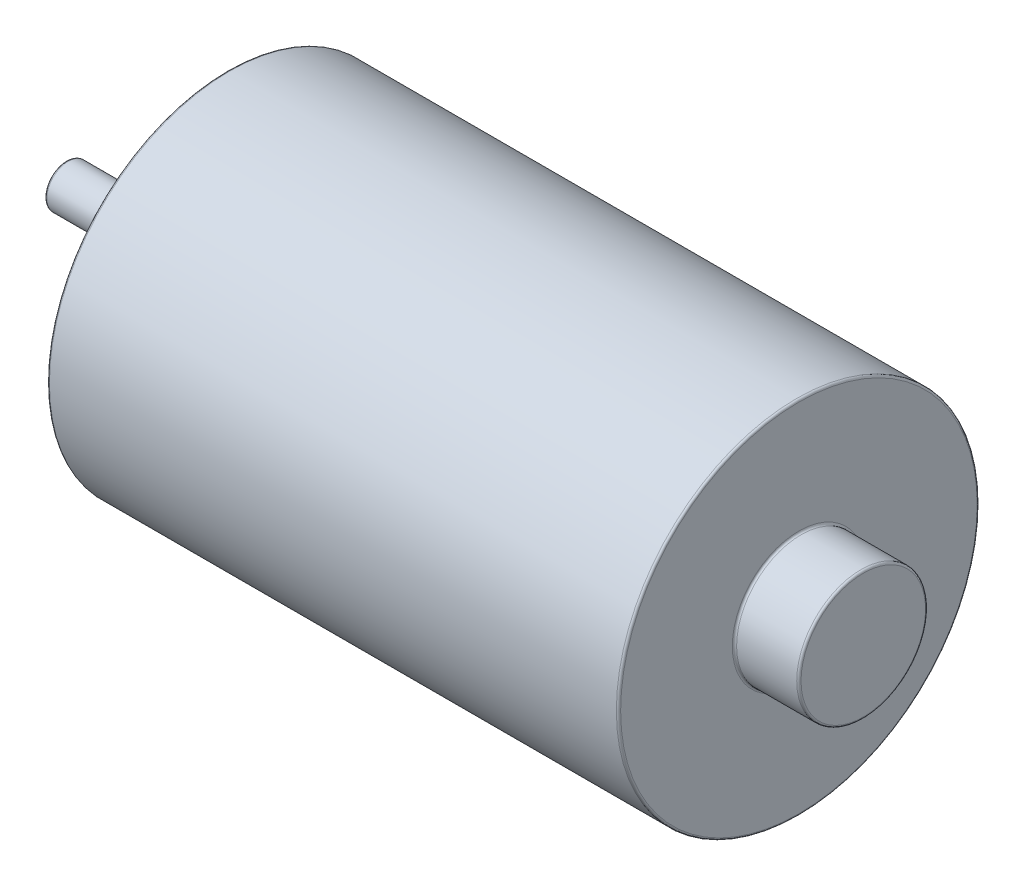
from build123d import *

# Parameters (mm, degrees)
FILLET1_R          = 0.25
SKETCH4_R          = 2
CUT_EXTRUDE2_DEPTH = 10


with BuildPart() as part:
    # Sketch1 → Revolve1 (revolve)
    with BuildSketch(Plane.XY):
        Polygon((-47.8, 2.5), (-47.8, 0), (45, 0), (45, 7.5), (37.5, 7.5), (37.5, 21), (-29, 21), (-29, 8.5), (-33, 8.5), (-33, 2.5), align=None)
    revolve(axis=Axis((-47.8, 0, 0), (1, 0, 0)))

    # Fillet1
    fillet1_edges = [part.edges().sort_by_distance(p)[0] for p in [
        (37.5, -21, 0),
        (-29, -21, 0),
        (-29, -8.5, 0),
        (-33, -8.5, 0),
        (-33, -2.5, 0),
        (-47.8, -2.5, 0),
        (45, -7.5, 0),
        (37.5, -7.5, 0),
    ]]
    fillet(fillet1_edges, radius=FILLET1_R)

    # Sketch4 → Cut-Extrude2 (cut)
    with BuildSketch(Plane.ZY.offset(29)):
        with Locations((0, 14.5)):
            Circle(SKETCH4_R)
        with Locations((0, -14.5)):
            Circle(SKETCH4_R)
    extrude(amount=-CUT_EXTRUDE2_DEPTH, mode=Mode.SUBTRACT)


solid = part.part
